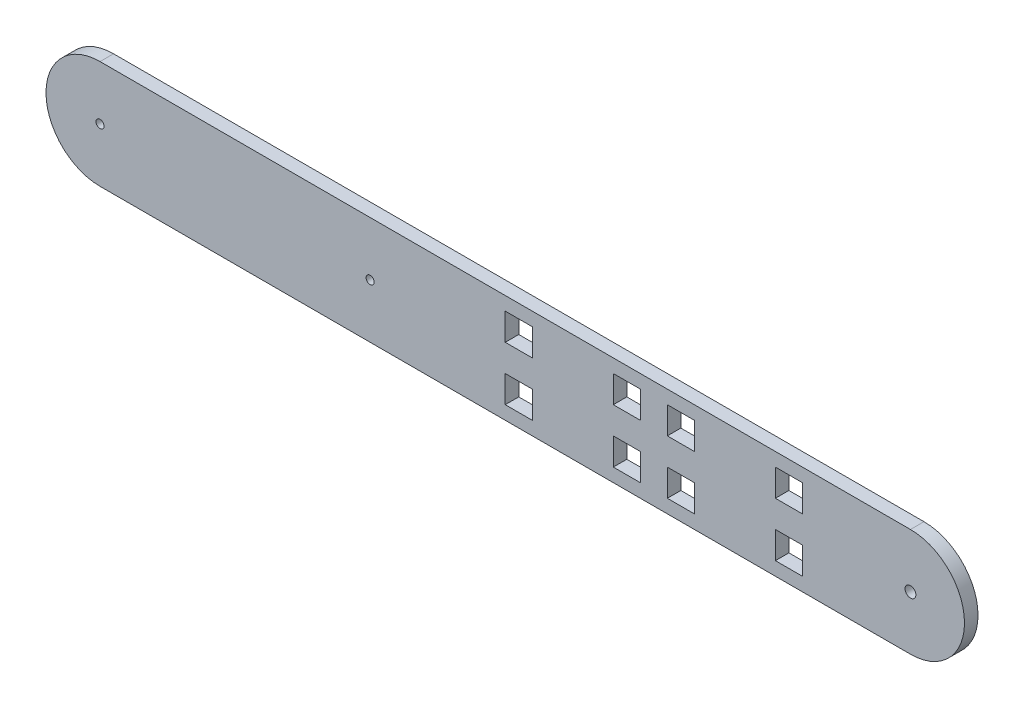
from build123d import *

# Parameters (mm, degrees)
SKETCH1_R           = 1.5
SKETCH1_R_2         = 2
SKETCH1_W           = 10
SKETCH1_H           = 10
BOSS_EXTRUDE1_DEPTH = 5


with BuildPart() as part:
    # Sketch1 → Boss-Extrude1 (new body)
    with BuildSketch(Plane.XY):
        with BuildLine():
            Line((-126.904376013, 20), (173.095623987, 20))
            ThreePointArc((173.095623987, 20), (193.095623987, 0), (173.095623987, -20))
            Line((173.095623987, -20), (-126.904376013, -20))
            ThreePointArc((-126.904376013, -20), (-146.904376013, 0), (-126.904376013, 20))
        make_face()
        with Locations((-126.904376013, 0)):
            Circle(SKETCH1_R, mode=Mode.SUBTRACT)
        with Locations((173.095623987, 0)):
            Circle(SKETCH1_R_2, mode=Mode.SUBTRACT)
        with Locations((-26.904376013, 0)):
            Circle(SKETCH1_R, mode=Mode.SUBTRACT)
        Polygon((63.095623987, 15), (73.095623987, 15), (73.095623987, 10), (73.095623987, 5), (63.095623987, 5), (63.095623987, 10), align=None, mode=Mode.SUBTRACT)
        Polygon((83.095623987, 10), (83.095623987, 5), (93.095623987, 5), (93.095623987, 10), (93.095623987, 15), (83.095623987, 15), align=None, mode=Mode.SUBTRACT)
        Polygon((123.095623987, 10), (123.095623987, 5), (133.095623987, 5), (133.095623987, 10), (133.095623987, 15), (123.095623987, 15), align=None, mode=Mode.SUBTRACT)
        Polygon((33.095623987, -15), (23.095623987, -15), (23.095623987, -10), (23.095623987, -5), (33.095623987, -5), (33.095623987, -10), align=None, mode=Mode.SUBTRACT)
        Polygon((63.095623987, -15), (73.095623987, -15), (73.095623987, -10), (73.095623987, -5), (63.095623987, -5), (63.095623987, -10), align=None, mode=Mode.SUBTRACT)
        Polygon((83.095623987, -10), (83.095623987, -5), (93.095623987, -5), (93.095623987, -10), (93.095623987, -15), (83.095623987, -15), align=None, mode=Mode.SUBTRACT)
        Polygon((123.095623987, -5), (133.095623987, -5), (133.095623987, -10), (133.095623987, -15), (123.095623987, -15), (123.095623987, -10), align=None, mode=Mode.SUBTRACT)
        with Locations((28.095623987, 10)):
            Rectangle(SKETCH1_W, SKETCH1_H, mode=Mode.SUBTRACT)
    extrude(amount=BOSS_EXTRUDE1_DEPTH)


solid = part.part
